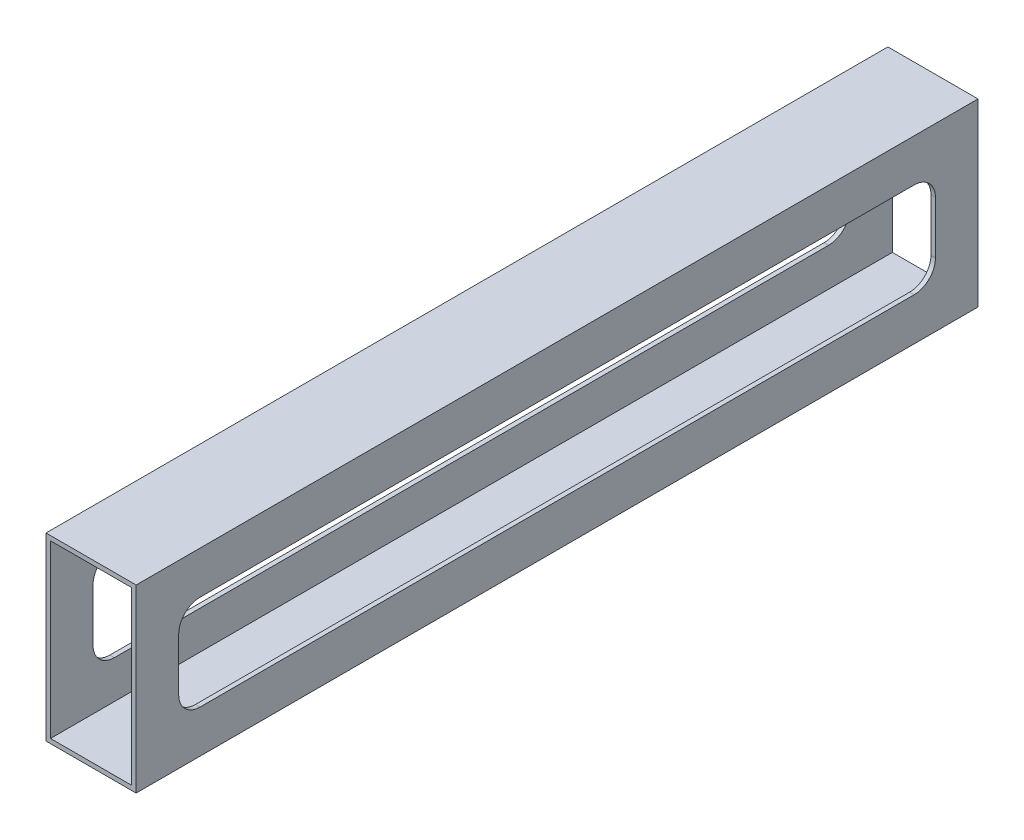
from build123d import *

# Parameters (mm, degrees)
SKETCH1_W           = 25.4
SKETCH1_H           = 50.8
SKETCH1_W_2         = 22.86
SKETCH1_H_2         = 48.26
BOSS_EXTRUDE1_DEPTH = 237.2995
CUT_EXTRUDE5_DEPTH  = 26.4


with BuildPart() as part:
    # Sketch1 → Boss-Extrude1 (new body)
    with BuildSketch(Plane.XY):
        with Locations((-102.657065342, -11.879495554)):
            Rectangle(SKETCH1_W, SKETCH1_H)
        with Locations((-102.657065342, -11.879495554)):
            Rectangle(SKETCH1_W_2, SKETCH1_H_2, mode=Mode.SUBTRACT)
    extrude(amount=BOSS_EXTRUDE1_DEPTH)

    # Sketch4 → Cut-Extrude5 (cut, through all)
    with BuildSketch(Plane(origin=(-89.957065342, 0, 0), x_dir=(0, 0, -1), z_dir=(1, 0, 0))):
        with BuildLine():
            Line((-18, 1.520504446), (-219.2995, 1.520504446))
            ThreePointArc((-219.2995, 1.520504446), (-223.542140687, -0.236854867), (-225.2995, -4.479495554))
            Line((-225.2995, -4.479495554), (-225.2995, -19.279495554))
            ThreePointArc((-225.2995, -19.279495554), (-223.542140687, -23.522136241), (-219.2995, -25.279495554))
            Line((-219.2995, -25.279495554), (-18, -25.279495554))
            ThreePointArc((-18, -25.279495554), (-13.757359313, -23.522136241), (-12, -19.279495554))
            Line((-12, -19.279495554), (-12, -4.479495554))
            ThreePointArc((-12, -4.479495554), (-13.757359313, -0.236854867), (-18, 1.520504446))
        make_face()
    extrude(amount=-CUT_EXTRUDE5_DEPTH, mode=Mode.SUBTRACT)


solid = part.part
